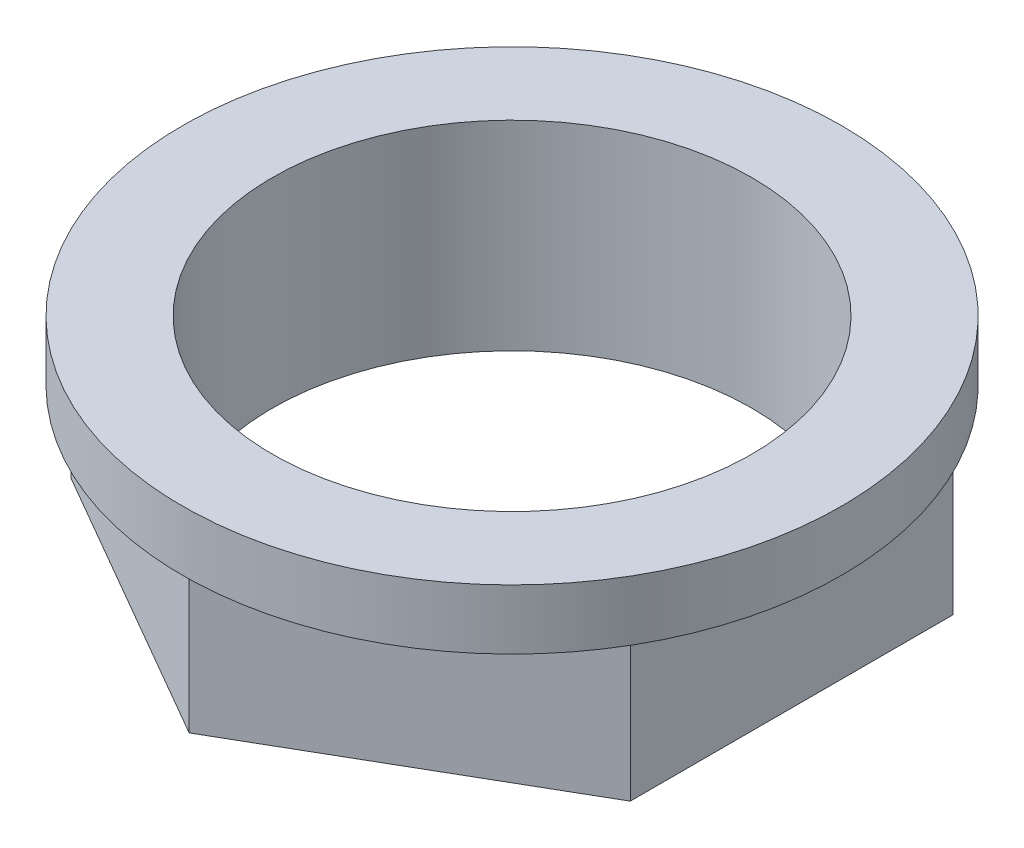
from build123d import *

# Parameters (mm, degrees)
SKETCH1_W          = 2.25
SKETCH1_H          = 5
SKETCH2_R          = 8.25
CUT_EXTRUDE1_DEPTH = 3.5


with BuildPart() as part:
    # Sketch1 → Revolve1 (revolve)
    with BuildSketch(Plane.XY):
        with Locations((-7.125, -2.5)):
            Rectangle(SKETCH1_W, SKETCH1_H)
    revolve(axis=Axis((0, -3.49659483, 0), (0, 1, 0)))

    # Sketch2 → Cut-Extrude1 (cut)
    with BuildSketch(Plane.XZ.offset(5)):
        Circle(SKETCH2_R)
        Polygon((0, 8.082903769), (-7, 4.041451884), (-7, -4.041451884), (0, -8.082903769), (7, -4.041451884), (7, 4.041451884), align=None, mode=Mode.SUBTRACT)
    extrude(amount=-CUT_EXTRUDE1_DEPTH, mode=Mode.SUBTRACT)


solid = part.part
